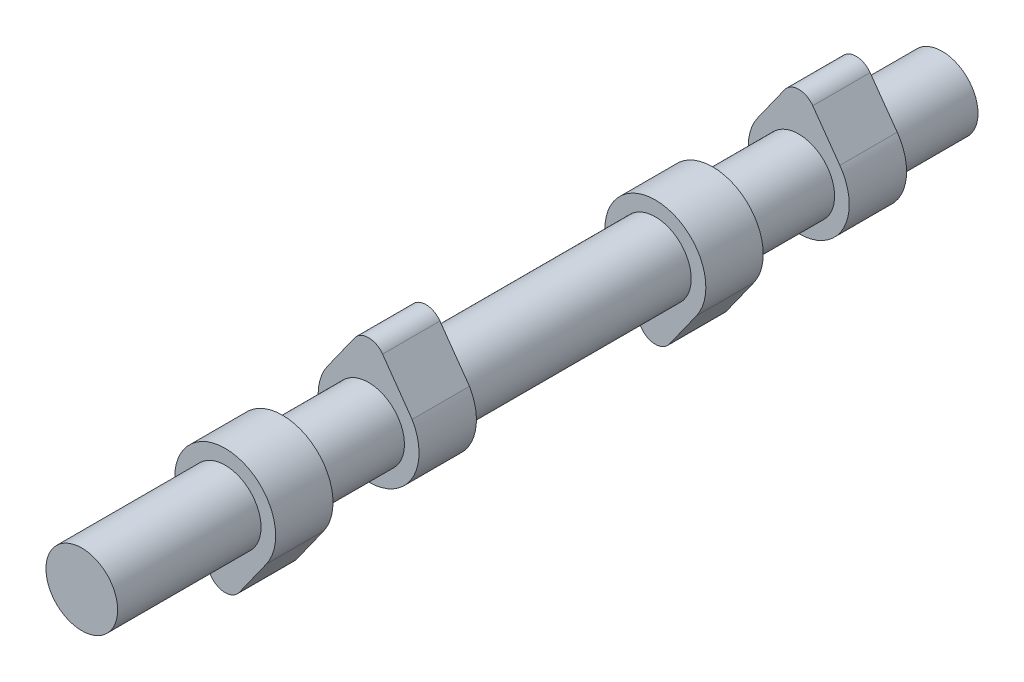
from build123d import *

# Parameters (mm, degrees)
SKETCH1_R           = 6.25
BOSS_EXTRUDE1_DEPTH = 125
SKETCH3_R           = 6.25
BOSS_EXTRUDE2_DEPTH = 10
SKETCH6_R           = 6.25
BOSS_EXTRUDE3_DEPTH = 10
SKETCH8_R           = 6.25
BOSS_EXTRUDE4_DEPTH = 10
SKETCH9_R           = 6.25
BOSS_EXTRUDE6_DEPTH = 10
SKETCH14_R          = 6.25
BOSS_EXTRUDE7_DEPTH = 25


with BuildPart() as part:
    # Sketch1 → Boss-Extrude1 (new body)
    with BuildSketch(Plane.XY):
        Circle(SKETCH1_R)
    extrude(amount=BOSS_EXTRUDE1_DEPTH)

    # Sketch3 → Boss-Extrude2 (add)
    with BuildSketch(Plane(origin=(0, 0, 15), x_dir=(-1, 0, 0), z_dir=(0, 0, -1))):
        with BuildLine():
            Line((-2.443849423, 11.74), (-7.168624973, 5.104))
            ThreePointArc((-7.168624973, 5.104), (0, -8.8), (7.168624973, 5.104))
            Line((7.168624973, 5.104), (2.443849423, 11.74))
            ThreePointArc((2.443849423, 11.74), (0, 13), (-2.443849423, 11.74))
        make_face()
        Circle(SKETCH3_R, mode=Mode.SUBTRACT)
    extrude(amount=-BOSS_EXTRUDE2_DEPTH)

    # Sketch6 → Boss-Extrude3 (add)
    with BuildSketch(Plane(origin=(0, 0, 40), x_dir=(-1, 0, 0), z_dir=(0, 0, -1))):
        with BuildLine():
            Line((-2.443849423, -11.74), (-7.168624973, -5.104))
            ThreePointArc((-7.168624973, -5.104), (0, 8.8), (7.168624973, -5.104))
            Line((7.168624973, -5.104), (2.443849423, -11.74))
            ThreePointArc((2.443849423, -11.74), (0, -13), (-2.443849423, -11.74))
        make_face()
        Circle(SKETCH6_R, mode=Mode.SUBTRACT)
    extrude(amount=-BOSS_EXTRUDE3_DEPTH)

    # Sketch8 → Boss-Extrude4 (add)
    with BuildSketch(Plane(origin=(0, 0, 90), x_dir=(-1, 0, 0), z_dir=(0, 0, -1))):
        with BuildLine():
            ThreePointArc((2.443849423, 11.74), (0, 13), (-2.443849423, 11.74))
            Line((-2.443849423, 11.74), (-2.456936947, 11.721470546))
            Line((-2.456936947, 11.721470546), (-6.737843427, 5.66051817))
            Line((-6.737843427, 5.66051817), (-7.587481927, 4.457591055))
            ThreePointArc((-7.587481927, 4.457591055), (0.385125198, -8.791568608), (7.168624973, 5.104))
            Line((7.168624973, 5.104), (2.443849423, 11.74))
        make_face()
        Circle(SKETCH8_R, mode=Mode.SUBTRACT)
    extrude(amount=-BOSS_EXTRUDE4_DEPTH)

    # Sketch9 → Boss-Extrude6 (add)
    with BuildSketch(Plane(origin=(0, 0, 115), x_dir=(-1, 0, 0), z_dir=(0, 0, -1))):
        with BuildLine():
            Line((2.443849423, -11.74), (7.168624973, -5.104))
            ThreePointArc((7.168624973, -5.104), (0, 8.8), (-7.168624973, -5.104))
            Line((-7.168624973, -5.104), (-2.443849423, -11.74))
            ThreePointArc((-2.443849423, -11.74), (0, -13), (2.443849423, -11.74))
        make_face()
        Circle(SKETCH9_R, mode=Mode.SUBTRACT)
    extrude(amount=-BOSS_EXTRUDE6_DEPTH)

    # Sketch14 → Boss-Extrude7 (add)
    with BuildSketch(Plane.XY.offset(125)):
        Circle(SKETCH14_R)
    extrude(amount=BOSS_EXTRUDE7_DEPTH)


solid = part.part
